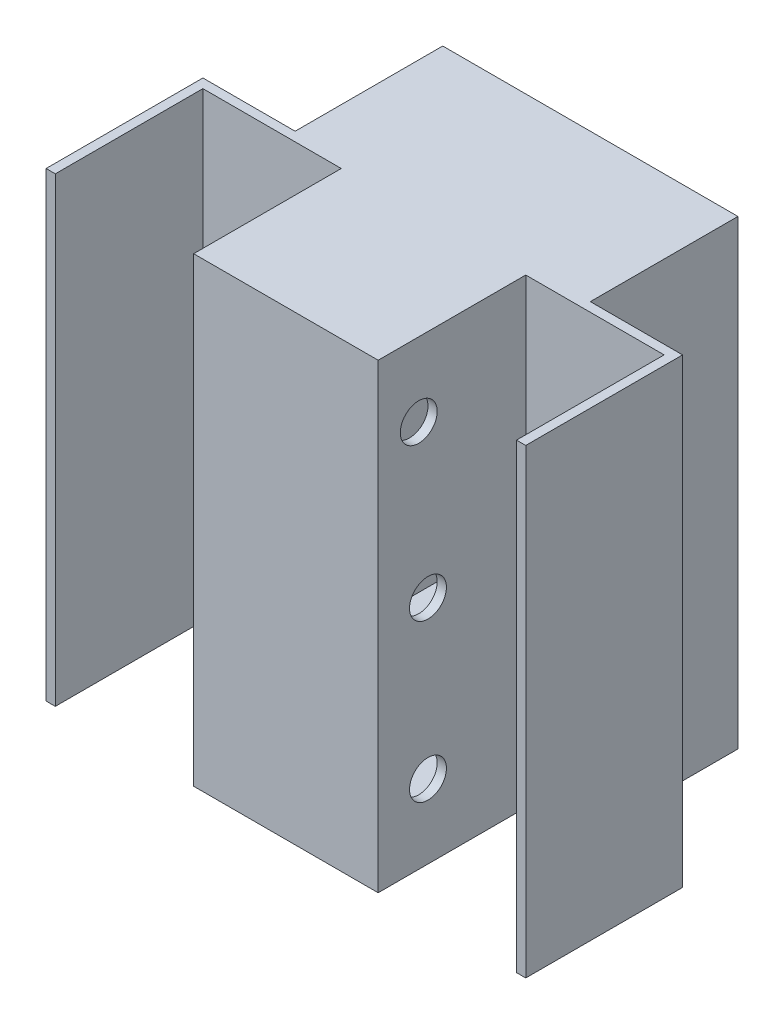
from build123d import *

# Parameters (mm, degrees)
ESQUISSE1_W             = 45
ESQUISSE1_H             = 250
BOSS_EXTRU_1_DEPTH      = 5
ESQUISSE2_W             = 80
ESQUISSE2_H             = 250
BOSS_EXTRU_2_DEPTH      = 5
ESQUISSE4_W             = 80
ESQUISSE4_H             = 250
BOSS_EXTRU_4_DEPTH      = 5
ESQUISSE5_W             = 85
ESQUISSE5_H             = 250
BOSS_EXTRU_5_DEPTH      = 5
ESQUISSE6_R             = 10
ENL_V_MAT_EXTRU_1_DEPTH = 5
ESQUISSE8_W             = 5
ESQUISSE8_H             = 250
BOSS_EXTRU_6_DEPTH      = 80
BOSS_EXTRU_7_DEPTH      = 5
BOSS_EXTRU_9_DEPTH      = 5


with BuildPart() as part:
    # Esquisse1 → Boss.-Extru.1 (new body)
    with BuildSketch(Plane.XY):
        with Locations((-22.5, 125)):
            Rectangle(ESQUISSE1_W, ESQUISSE1_H)
    boss_extru_1 = extrude(amount=BOSS_EXTRU_1_DEPTH)

    # Esquisse2 → Boss.-Extru.2 (add)
    with BuildSketch(Plane(origin=(0, 0, 0), x_dir=(0, 0, -1), z_dir=(1, 0, 0))):
        with Locations((35, 125)):
            Rectangle(ESQUISSE2_W, ESQUISSE2_H)
    boss_extru_2 = extrude(amount=BOSS_EXTRU_2_DEPTH)

    # Esquisse4 → Boss.-Extru.4 (add)
    with BuildSketch(Plane(origin=(0, 0, -75), x_dir=(-1, 0, 0), z_dir=(0, 0, -1))):
        with Locations((-40, 125)):
            Rectangle(ESQUISSE4_W, ESQUISSE4_H)
    boss_extru_4 = extrude(amount=BOSS_EXTRU_4_DEPTH)

    # Esquisse5 → Boss.-Extru.5 (add)
    with BuildSketch(Plane(origin=(80, 0, 0), x_dir=(0, 0, -1), z_dir=(1, 0, 0))):
        with Locations((37.5, 125)):
            Rectangle(ESQUISSE5_W, ESQUISSE5_H)
    boss_extru_5 = extrude(amount=BOSS_EXTRU_5_DEPTH)

    # Esquisse6 → Enlèv. mat.-Extru.1 (cut)
    with BuildSketch(Plane(origin=(5, 0, 0), x_dir=(0, 0, -1), z_dir=(1, 0, 0))):
        with Locations((22, 40)):
            Circle(ESQUISSE6_R)
        with Locations((22, 125)):
            Circle(ESQUISSE6_R)
        with Locations((17, 210)):
            Circle(ESQUISSE6_R)
    enl_v_mat_extru_1 = extrude(amount=-ENL_V_MAT_EXTRU_1_DEPTH, mode=Mode.SUBTRACT)

    # Esquisse8 → Boss.-Extru.6 (add)
    with BuildSketch(Plane(origin=(0, 0, -80), x_dir=(-1, 0, 0), z_dir=(0, 0, -1))):
        with Locations((-32.5, 125)):
            Rectangle(ESQUISSE8_W, ESQUISSE8_H)
    boss_extru_6 = extrude(amount=BOSS_EXTRU_6_DEPTH)

    # Symétrie2: Boss.-Extru.1, Boss.-Extru.2, Boss.-Extru.4, Boss.-Extru.5, Enlèv. mat.-Extru.1, Boss.-Extru.6 across plane
    add(boss_extru_1.mirror(Plane(origin=(-45, 0, 5), x_dir=(0, 0, 1), z_dir=(1, 0, 0))))
    add(boss_extru_2.mirror(Plane(origin=(-45, 0, 5), x_dir=(0, 0, 1), z_dir=(1, 0, 0))))
    add(boss_extru_4.mirror(Plane(origin=(-45, 0, 5), x_dir=(0, 0, 1), z_dir=(1, 0, 0))))
    add(boss_extru_5.mirror(Plane(origin=(-45, 0, 5), x_dir=(0, 0, 1), z_dir=(1, 0, 0))))
    add(enl_v_mat_extru_1.mirror(Plane(origin=(-45, 0, 5), x_dir=(0, 0, 1), z_dir=(1, 0, 0))), mode=Mode.SUBTRACT)
    add(boss_extru_6.mirror(Plane(origin=(-45, 0, 5), x_dir=(0, 0, 1), z_dir=(1, 0, 0))))

    # Esquisse3D1 → Boss.-Extru.7 (add)
    with BuildSketch(Plane(origin=(30, 0, -160), x_dir=(-0.5999999999999998, 0, 0.8000000000000003), z_dir=(0, -1, 0))):
        Polygon((0, 0), (64, -48), (82, -24), (146, -72), (200, 0), (136, 48), (154, 72), (90, 120), align=None)
    extrude(amount=-BOSS_EXTRU_7_DEPTH)

    # Esquisse3D3 → Boss.-Extru.9 (add)
    with BuildSketch(Plane(origin=(-120, 250, -160), x_dir=(0.5999999999999999, 0, 0.8), z_dir=(0, 1, 0))):
        Polygon((0, 0), (64, -48), (82, -24), (146, -72), (200, 0), (136, 48), (154, 72), (90, 120), align=None)
    extrude(amount=-BOSS_EXTRU_9_DEPTH)


solid = part.part
